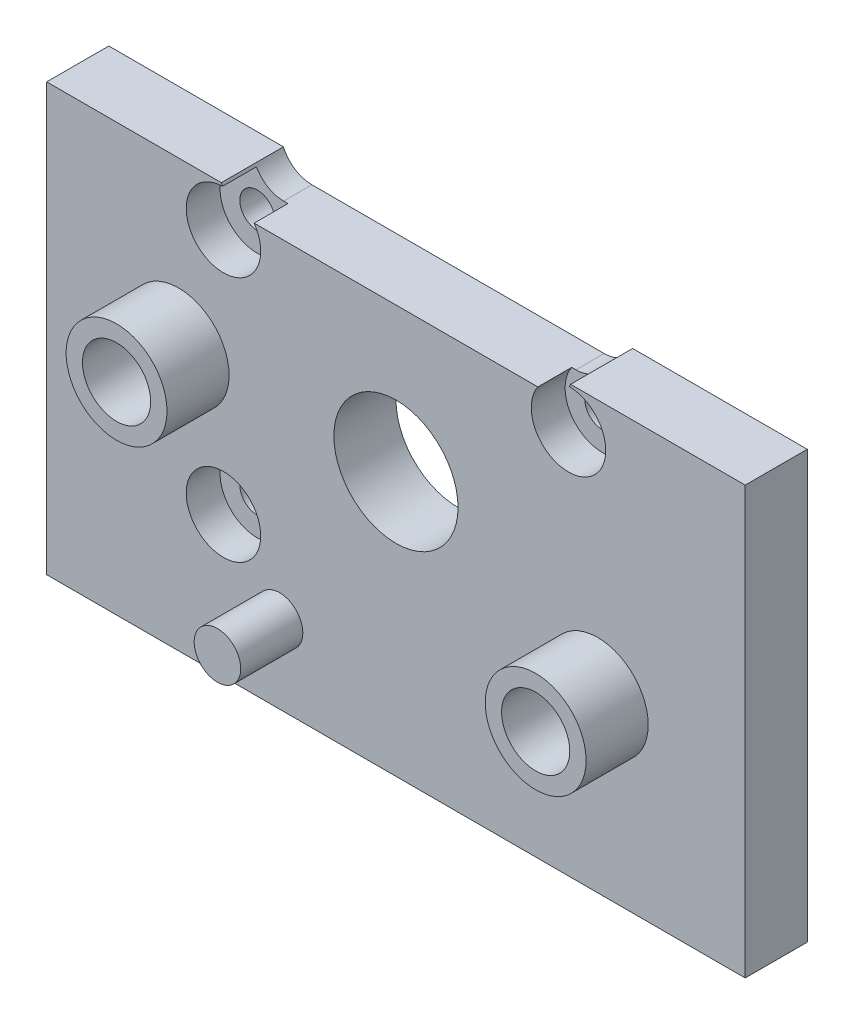
from build123d import *

# Parameters (mm, degrees)
SKETCH1_W                                        = 45
SKETCH1_H                                        = 27.5
BOSS_EXTRUDE1_DEPTH                              = 4
CUT_EXTRUDE1_DEPTH                               = 5
SKETCH3_W                                        = 3.25
SKETCH3_H                                        = 4
SKETCH4_W                                        = 1.5
SKETCH4_H                                        = 4
SKETCH5_W                                        = 3.25
SKETCH5_H                                        = 4
F_8_0_8_DIAMETER_HOLE1_D                         = 8
F_8_0_8_DIAMETER_HOLE1_DEPTH                     = 8
CBORE_FOR_M2_HEX_HEAD_MACHINE_SCREW1_D           = 2.26
CBORE_FOR_M2_HEX_HEAD_MACHINE_SCREW1_DEPTH       = 4
CBORE_FOR_M2_HEX_HEAD_MACHINE_SCREW1_CBORE_D     = 4.8
CBORE_FOR_M2_HEX_HEAD_MACHINE_SCREW1_CBORE_DEPTH = 2.18
TAPPED_HOLE_FOR_8_32_HELICOIL1_D                 = 4.3942
TAPPED_HOLE_FOR_8_32_HELICOIL1_DEPTH             = 13.335
TAPPED_HOLE_FOR_8_32_HELICOIL1_TIP               = 1.320150866


with BuildPart() as part:
    # Sketch1 → Boss-Extrude1 (new body)
    with BuildSketch(Plane.XY.offset(4)):
        with Locations((0, -3.25)):
            Rectangle(SKETCH1_W, SKETCH1_H)
    extrude(amount=-BOSS_EXTRUDE1_DEPTH)

    # Sketch2 → Cut-Extrude1 (cut, through all)
    with BuildSketch(Plane(origin=(0, 0, 0), x_dir=(-1, 0, 0), z_dir=(0, 0, -1))):
        with BuildLine():
            Line((-9.416969722, 9.3), (9.416969722, 9.3))
            ThreePointArc((9.416969722, 9.3), (10.512414837, 9.626679947), (11.25, 10.5))
            Line((11.25, 10.5), (-11.25, 10.5))
            ThreePointArc((-11.25, 10.5), (-10.512414837, 9.626679947), (-9.416969722, 9.3))
        make_face()
    extrude(amount=-CUT_EXTRUDE1_DEPTH, mode=Mode.SUBTRACT)

    # Sketch3 → Revolve1 (revolve)
    with BuildSketch(Plane(origin=(0, -6, 0), x_dir=(1, 0, 0), z_dir=(0, 1, 0))):
        with Locations((14.625, -6)):
            Rectangle(SKETCH3_W, SKETCH3_H)
    revolve(axis=Axis((13, -6, 4), (0, 0, 1)))

    # Sketch4 → Revolve2 (revolve)
    with BuildSketch(Plane(origin=(0, -12, 0), x_dir=(1, 0, 0), z_dir=(0, 1, 0))):
        with Locations((-6.75, -6)):
            Rectangle(SKETCH4_W, SKETCH4_H)
    revolve(axis=Axis((-7.5, -12, 4), (0, 0, 1)))

    # Sketch5 → Revolve3 (revolve)
    with BuildSketch(Plane(origin=(0, 0, 0), x_dir=(1, 0, 0), z_dir=(0, 1, 0))):
        with Locations((-12.375, -6)):
            Rectangle(SKETCH5_W, SKETCH5_H)
    revolve(axis=Axis((-14, 0, 4), (0, 0, 1)))

    # Ø8.0 (8) Diameter Hole1
    with Locations(Plane(origin=(0, 0, 0), x_dir=(-1, 0, 0), z_dir=(0, 0, -1))):
        with Locations((0, 0)):
            Hole(F_8_0_8_DIAMETER_HOLE1_D / 2, depth=F_8_0_8_DIAMETER_HOLE1_DEPTH)

    # CBORE for M2 Hex Head Machine Screw1
    with Locations(Plane.XY.offset(4)):
        with Locations((-11.113, -7.942), (-11.113, 7.938), (11.117, 7.938)):
            CounterBoreHole(CBORE_FOR_M2_HEX_HEAD_MACHINE_SCREW1_D / 2, CBORE_FOR_M2_HEX_HEAD_MACHINE_SCREW1_CBORE_D / 2, CBORE_FOR_M2_HEX_HEAD_MACHINE_SCREW1_CBORE_DEPTH, depth=CBORE_FOR_M2_HEX_HEAD_MACHINE_SCREW1_DEPTH)

    # Tapped Hole for #8-32 Helicoil1
    with Locations(Plane.XY.offset(8)):
        with Locations((-14, 0), (13, -6)):
            Hole(TAPPED_HOLE_FOR_8_32_HELICOIL1_D / 2, depth=TAPPED_HOLE_FOR_8_32_HELICOIL1_DEPTH)
            with Locations((0, 0, -(TAPPED_HOLE_FOR_8_32_HELICOIL1_DEPTH + TAPPED_HOLE_FOR_8_32_HELICOIL1_TIP / 2))):  # 118° drill point
                Cone(0, TAPPED_HOLE_FOR_8_32_HELICOIL1_D / 2, TAPPED_HOLE_FOR_8_32_HELICOIL1_TIP, mode=Mode.SUBTRACT)


solid = part.part
